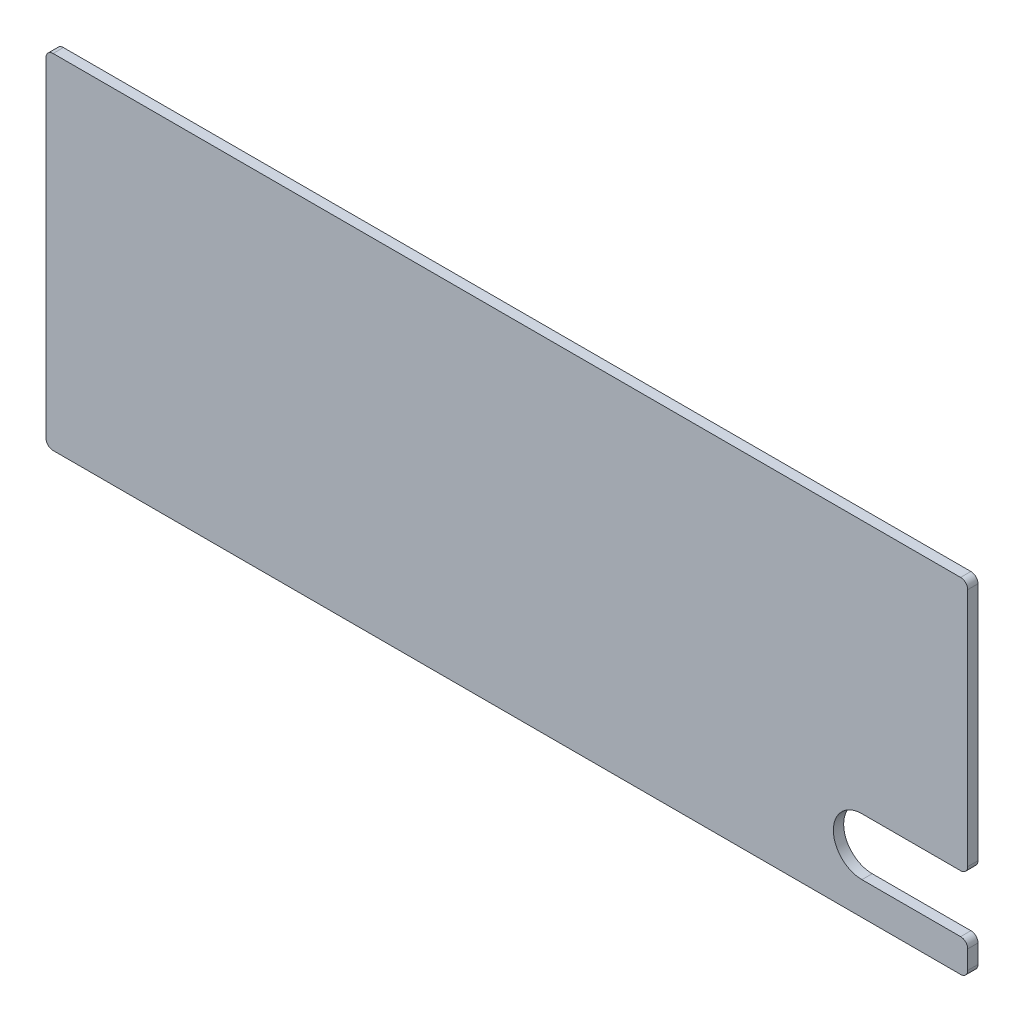
from build123d import *

# Parameters (mm, degrees)
SCHIZZO1_W                   = 130
SCHIZZO1_H                   = 48.5
ESTRUSIONE_ESTRUSIONE1_DEPTH = 1.45
TAGLIO_ESTRUSIONE1_DEPTH     = 12
RACCORDO1_R                  = 1


with BuildPart() as part:
    # Schizzo1 → Estrusione-Estrusione1 (new body)
    with BuildSketch(Plane.XY):
        with Locations((65, 24.25)):
            Rectangle(SCHIZZO1_W, SCHIZZO1_H)
    extrude(amount=ESTRUSIONE_ESTRUSIONE1_DEPTH)

    # Schizzo2 → Taglio-Estrusione1 (cut)
    with BuildSketch(Plane.XY.offset(1.45)):
        with BuildLine():
            Line((144.922454277, 4.622930456), (115.077545723, 4.622930456))
            ThreePointArc((115.077545723, 4.622930456), (111.052124488, 8.64835169), (115.077545723, 12.673772925))
            Line((115.077545723, 12.673772925), (144.922454277, 12.673772925))
            ThreePointArc((144.922454277, 12.673772925), (148.947875512, 8.64835169), (144.922454277, 4.622930456))
        make_face()
    extrude(amount=-TAGLIO_ESTRUSIONE1_DEPTH, mode=Mode.SUBTRACT)

    # Raccordo1
    raccordo1_edges = [part.edges().sort_by_distance(p)[0] for p in [
        (130, 4.622930456, 0.725),
        (130, 12.673772925, 0.725),
        (0, 48.5, 0.725),
        (130, 48.5, 0.725),
        (130, 0, 0.725),
        (0, 0, 0.725),
    ]]
    fillet(raccordo1_edges, radius=RACCORDO1_R)


solid = part.part
